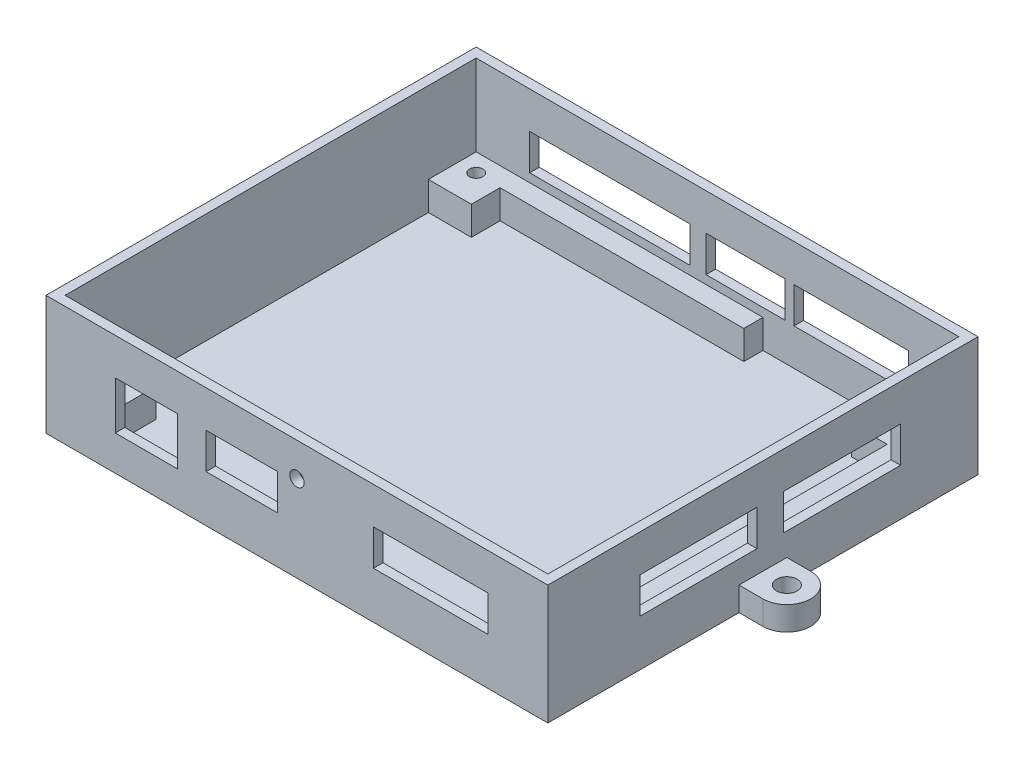
from build123d import *

# Parameters (mm, degrees)
SKETCH_1_W          = 105
SKETCH_1_H          = 90
EXTRUDE_1_DEPTH     = 25
SHELL_1_T           = -2
SKETCH_8_R          = 2.15
EXTRUDE_3_DEPTH     = 5
SKETCH_3_W          = 24
SKETCH_3_H          = 7.5
SKETCH_3_W_2        = 14.9
CUT_EXTRUDE_2_DEPTH = 10
SKETCH_5_W          = 24.5
SKETCH_5_H          = 7.5
CUT_EXTRUDE_3_DEPTH = 10
SKETCH_7_W          = 33.5
SKETCH_7_H          = 7.5
SKETCH_7_W_2        = 16.5
SKETCH_7_W_3        = 24
CUT_EXTRUDE_4_DEPTH = 10
SKETCH_9_R          = 1.5
CUT_EXTRUDE_5_DEPTH = 50
SKETCH_2_R          = 1.4
SKETCH_2_W          = 9
SKETCH_2_H          = 10
EXTRUDE_6_DEPTH     = 6
SKETCH_3_8_W        = 24
SKETCH_3_8_H        = 7.5
SKETCH_3_8_W_2      = 14.9
SKETCH_3_8_W_3      = 13
SKETCH_3_8_H_2      = 10
CUT_EXTRUDE_6_DEPTH = 10


with BuildPart() as part:
    # 草图1 → 凸台-拉伸1 (new body)
    with BuildSketch(Plane(origin=(0, 0, 0), x_dir=(1, 0, 0), z_dir=(0, 1, 0))):
        Rectangle(SKETCH_1_W, SKETCH_1_H)
    extrude(amount=EXTRUDE_1_DEPTH)

    # 抽壳1
    shell_1_openings = [part.faces().sort_by_distance(p)[0] for p in [
        (0, 25, 0),
    ]]
    offset(amount=SHELL_1_T, openings=shell_1_openings, kind=Kind.INTERSECTION)

    # 草图8 → 凸台-拉伸3 (add)
    # profile 1 of 2: a face of its own
    with BuildSketch(Plane.XZ):
        with BuildLine():
            Line((-57.5, 5), (-52.5, 5))
            Line((-52.5, 5), (-52.5, -5))
            Line((-52.5, -5), (-57.5, -5))
            ThreePointArc((-57.5, -5), (-62.5, 0), (-57.5, 5))
        make_face()
        with Locations((-57.5, 0)):
            Circle(SKETCH_8_R, mode=Mode.SUBTRACT)
    # profile 2 of 2: a face of its own
    with BuildSketch(Plane.XZ):
        with BuildLine():
            Line((52.5, -5), (57.5, -5))
            ThreePointArc((57.5, -5), (62.5, 0), (57.5, 5))
            Line((57.5, 5), (52.5, 5))
            Line((52.5, 5), (52.5, -5))
        make_face()
        with Locations((57.5, 0)):
            Circle(SKETCH_8_R, mode=Mode.SUBTRACT)
    extrude(amount=-EXTRUDE_3_DEPTH)

    # 草图3 → 切除-拉伸2 (cut)
    with BuildSketch(Plane.XY.offset(45)):
        with Locations((28, 13.55)):
            Rectangle(SKETCH_3_W, SKETCH_3_H)
        with Locations((-11.55, 13.55)):
            Rectangle(SKETCH_3_W_2, SKETCH_3_H)
    extrude(amount=-CUT_EXTRUDE_2_DEPTH, mode=Mode.SUBTRACT)

    # 草图5 → 切除-拉伸3 (cut)
    with BuildSketch(Plane(origin=(52.5, 0, 0), x_dir=(0, 0, -1), z_dir=(1, 0, 0))):
        with Locations((16.55, 13.55)):
            Rectangle(SKETCH_5_W, SKETCH_5_H)
        with Locations((-13.5, 13.471843212)):
            Rectangle(SKETCH_5_W, SKETCH_5_H)
    extrude(amount=-CUT_EXTRUDE_3_DEPTH, mode=Mode.SUBTRACT)

    # 草图7 → 切除-拉伸4 (cut)
    with BuildSketch(Plane(origin=(0, 0, -45), x_dir=(-1, 0, 0), z_dir=(0, 0, -1))):
        with Locations((22.55, 13.55)):
            Rectangle(SKETCH_7_W, SKETCH_7_H)
        with Locations((-5.85, 13.55)):
            Rectangle(SKETCH_7_W_2, SKETCH_7_H)
        with Locations((-28, 13.452632976)):
            Rectangle(SKETCH_7_W_3, SKETCH_7_H)
    extrude(amount=-CUT_EXTRUDE_4_DEPTH, mode=Mode.SUBTRACT)

    # 草图9 → 切除-拉伸5 (cut)
    with BuildSketch(Plane.XY):
        with Locations((0, 18)):
            Circle(SKETCH_9_R)
    extrude(amount=CUT_EXTRUDE_5_DEPTH, mode=Mode.SUBTRACT)

    # 草图2 → 凸台-拉伸6 (add)
    # profile 1 of 3: a face of its own
    with BuildSketch(Plane(origin=(0, 2, 0), x_dir=(1, 0, 0), z_dir=(0, 1, 0))):
        Polygon((-41.5, 33), (-41.5, 39), (9.5, 39), (9.5, 43), (-50.5, 43), (-50.5, 33), align=None)
        with Locations((-46.689481309, 39.196373095)):
            Circle(SKETCH_2_R, mode=Mode.SUBTRACT)
    # profile 2 of 3: a face of its own
    with BuildSketch(Plane(origin=(0, 2, 0), x_dir=(1, 0, 0), z_dir=(0, 1, 0))):
        with Locations((-46, -38)):
            Rectangle(SKETCH_2_W, SKETCH_2_H)
        with Locations((-46.725108279, -39.220894808)):
            Circle(SKETCH_2_R, mode=Mode.SUBTRACT)
    # profile 3 of 3: a face of its own
    with BuildSketch(Plane(origin=(0, 2, 0), x_dir=(1, 0, 0), z_dir=(0, 1, 0))):
        with BuildLine():
            Line((50.5, 43), (38, 43))
            Line((38, 43), (38, 33))
            Line((38, 33), (45.5, 33))
            Line((45.5, 33), (45.5, -32.46))
            ThreePointArc((45.5, -32.46), (45.048944443, -33.548944443), (43.96, -34))
            Line((43.96, -34), (42.04, -34))
            ThreePointArc((42.04, -34), (40.951055557, -34.451055557), (40.5, -35.54))
            Line((40.5, -35.54), (40.5, -43))
            Line((40.5, -43), (50.5, -43))
            Line((50.5, -43), (50.5, 43))
        make_face()
        with Locations((46.687886977, -39.208970538)):
            Circle(SKETCH_2_R, mode=Mode.SUBTRACT)
        with Locations((46.691741848, 39.161577941)):
            Circle(SKETCH_2_R, mode=Mode.SUBTRACT)
    extrude(amount=EXTRUDE_6_DEPTH)

    # 草图3<8> → 切除-拉伸6 (cut)
    with BuildSketch(Plane.XY.offset(45)):
        with Locations((28, 13.55)):
            Rectangle(SKETCH_3_8_W, SKETCH_3_8_H)
        with Locations((-11.55, 13.55)):
            Rectangle(SKETCH_3_8_W_2, SKETCH_3_8_H)
        with Locations((-31.5, 12.3)):
            Rectangle(SKETCH_3_8_W_3, SKETCH_3_8_H_2)
    extrude(amount=-CUT_EXTRUDE_6_DEPTH, mode=Mode.SUBTRACT)


solid = part.part
